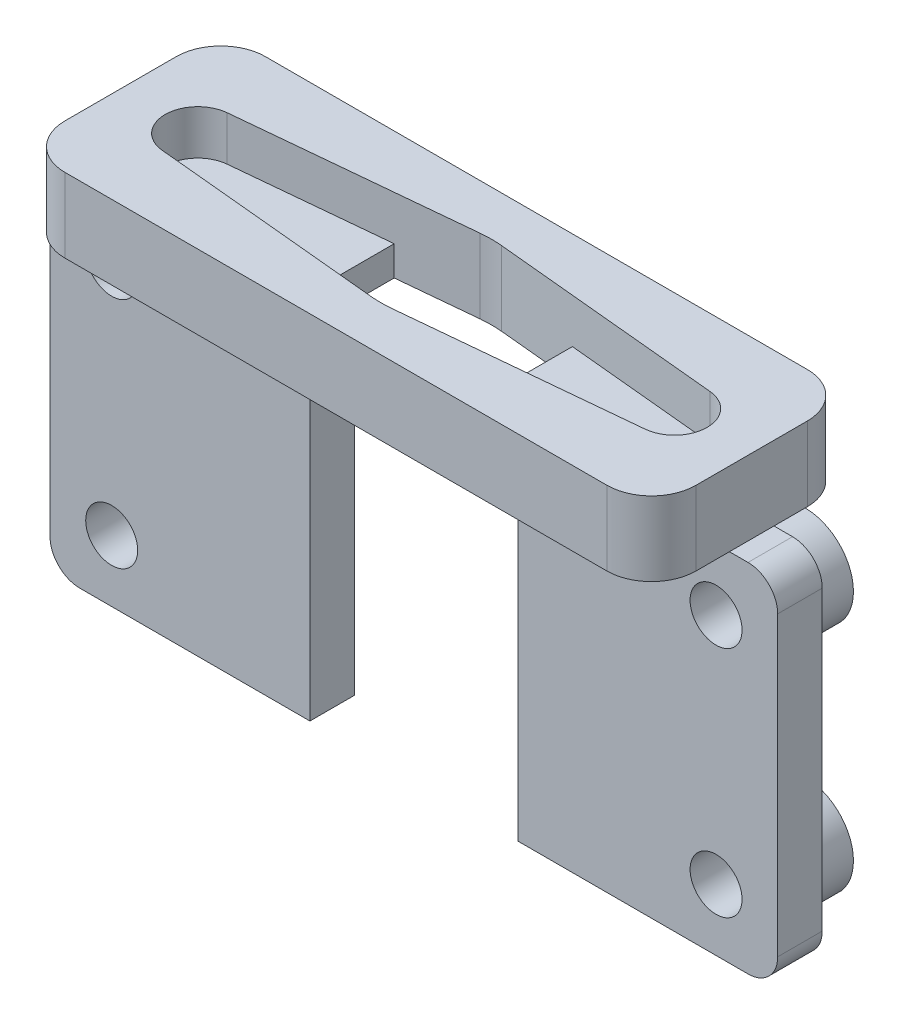
from build123d import *

# Parameters (mm, degrees)
BOSS_EXTRUDE1_DEPTH = 5
BOSS_EXTRUDE2_DEPTH = 2
SKETCH4_W           = 24
SKETCH4_H           = 3
BOSS_EXTRUDE3_DEPTH = 49
CUT_EXTRUDE1_REACH  = 10.25
SKETCH5_R           = 1.75
SKETCH5_W           = 14
SKETCH5_H           = 24
SKETCH6_R           = 3.25
SKETCH6_R_2         = 1.75
BOSS_EXTRUDE4_DEPTH = 3
FILLET1_R           = 2


with BuildPart() as part:
    # Sketch1 → Boss-Extrude1 (new body)
    with BuildSketch(Plane(origin=(0, 0, 0), x_dir=(1, 0, 0), z_dir=(0, 1, 0))):
        with BuildLine():
            Line((-18.25, 6.75), (18.25, 6.75))
            ThreePointArc((18.25, 6.75), (20.371320344, 5.871320344), (21.25, 3.75))
            Line((21.25, 3.75), (21.25, -3.75))
            ThreePointArc((21.25, -3.75), (20.371320344, -5.871320344), (18.25, -6.75))
            Line((18.25, -6.75), (-18.25, -6.75))
            ThreePointArc((-18.25, -6.75), (-20.371320344, -5.871320344), (-21.25, -3.75))
            Line((-21.25, -3.75), (-21.25, 3.75))
            ThreePointArc((-21.25, 3.75), (-20.371320344, 5.871320344), (-18.25, 6.75))
        make_face()
        with BuildLine():
            Line((16.260111444, 2.189943648), (0.716289014, 3.681276533))
            ThreePointArc((0.716289014, 3.681276533), (0, 3.715559552), (-0.716289014, 3.681276533))
            Line((-0.716289014, 3.681276533), (-16.260111444, 2.189943648))
            ThreePointArc((-16.260111444, 2.189943648), (-18.25, 0), (-16.260111444, -2.189943648))
            Line((-16.260111444, -2.189943648), (-0.716289014, -3.681276533))
            ThreePointArc((-0.716289014, -3.681276533), (0, -3.715559552), (0.716289014, -3.681276533))
            Line((0.716289014, -3.681276533), (16.260111444, -2.189943648))
            ThreePointArc((16.260111444, -2.189943648), (18.25, 0), (16.260111444, 2.189943648))
        make_face(mode=Mode.SUBTRACT)
    extrude(amount=BOSS_EXTRUDE1_DEPTH)

    # Sketch2 → Boss-Extrude2 (add)
    with BuildSketch(Plane.XZ):
        with BuildLine():
            Line((-16.260111444, 2.189943648), (-6, 3.174337395))
            Line((-6, 3.174337395), (-6, -3.174337395))
            Line((-6, -3.174337395), (-16.260111444, -2.189943648))
            ThreePointArc((-16.260111444, -2.189943648), (-18.25, 0), (-16.260111444, 2.189943648))
        make_face()
        with BuildLine():
            Line((6, -3.174337395), (16.260111444, -2.189943648))
            ThreePointArc((16.260111444, -2.189943648), (18.25, 0), (16.260111444, 2.189943648))
            Line((16.260111444, 2.189943648), (6, 3.174337395))
            Line((6, 3.174337395), (6, -3.174337395))
        make_face()
    extrude(amount=-BOSS_EXTRUDE2_DEPTH)

    # Sketch4 → Boss-Extrude3 (add)
    with BuildSketch(Plane(origin=(24.5, 24.5, 0), x_dir=(0, -1, 0), z_dir=(-1, 0, 0))):
        with Locations((36.5, 0)):
            Rectangle(SKETCH4_W, SKETCH4_H)
    extrude(amount=BOSS_EXTRUDE3_DEPTH)

    # Sketch5 → Cut-Extrude1 (cut, up to next)
    with BuildSketch(Plane(origin=(0, 0, -1.5), x_dir=(-1, 0, 0), z_dir=(0, 0, -1)), mode=Mode.PRIVATE) as cut_extrude1_sk1:
        with Locations((20.35, -19.85)):
            Circle(SKETCH5_R)
    cut_extrude1_tool1 = extrude(cut_extrude1_sk1.sketch, amount=-CUT_EXTRUDE1_REACH, mode=Mode.PRIVATE) & part.part
    add(cut_extrude1_tool1.solids().sort_by_distance((-20.35, -19.85, -1.5))[0], mode=Mode.SUBTRACT)
    # Sketch5 → Cut-Extrude1 (cut, up to next)
    with BuildSketch(Plane(origin=(0, 0, -1.5), x_dir=(-1, 0, 0), z_dir=(0, 0, -1)), mode=Mode.PRIVATE) as cut_extrude1_sk2:
        with Locations((-20.35, -19.85)):
            Circle(SKETCH5_R)
    cut_extrude1_tool2 = extrude(cut_extrude1_sk2.sketch, amount=-CUT_EXTRUDE1_REACH, mode=Mode.PRIVATE) & part.part
    add(cut_extrude1_tool2.solids().sort_by_distance((20.35, -19.85, -1.5))[0], mode=Mode.SUBTRACT)
    # Sketch5 → Cut-Extrude1 (cut, up to next)
    with BuildSketch(Plane(origin=(0, 0, -1.5), x_dir=(-1, 0, 0), z_dir=(0, 0, -1)), mode=Mode.PRIVATE) as cut_extrude1_sk3:
        with Locations((-20.35, -4.15)):
            Circle(SKETCH5_R)
    cut_extrude1_tool3 = extrude(cut_extrude1_sk3.sketch, amount=-CUT_EXTRUDE1_REACH, mode=Mode.PRIVATE) & part.part
    add(cut_extrude1_tool3.solids().sort_by_distance((20.35, -4.15, -1.5))[0], mode=Mode.SUBTRACT)
    # Sketch5 → Cut-Extrude1 (cut, up to next)
    with BuildSketch(Plane(origin=(0, 0, -1.5), x_dir=(-1, 0, 0), z_dir=(0, 0, -1)), mode=Mode.PRIVATE) as cut_extrude1_sk4:
        with Locations((20.35, -4.15)):
            Circle(SKETCH5_R)
    cut_extrude1_tool4 = extrude(cut_extrude1_sk4.sketch, amount=-CUT_EXTRUDE1_REACH, mode=Mode.PRIVATE) & part.part
    add(cut_extrude1_tool4.solids().sort_by_distance((-20.35, -4.15, -1.5))[0], mode=Mode.SUBTRACT)
    # Sketch5 → Cut-Extrude1 (cut, up to next)
    with BuildSketch(Plane(origin=(0, 0, -1.5), x_dir=(-1, 0, 0), z_dir=(0, 0, -1)), mode=Mode.PRIVATE) as cut_extrude1_sk5:
        with Locations((0, -12)):
            Rectangle(SKETCH5_W, SKETCH5_H)
    cut_extrude1_tool5 = extrude(cut_extrude1_sk5.sketch, amount=-CUT_EXTRUDE1_REACH, mode=Mode.PRIVATE) & part.part
    add(cut_extrude1_tool5.solids().sort_by_distance((0, -12, -1.5))[0], mode=Mode.SUBTRACT)

    # Sketch6 → Boss-Extrude4 (add)
    with BuildSketch(Plane(origin=(0, 0, -1.5), x_dir=(-1, 0, 0), z_dir=(0, 0, -1))):
        with Locations((-20.35, -4.15)):
            Circle(SKETCH6_R)
        with Locations((-20.35, -4.15)):
            Circle(SKETCH6_R_2, mode=Mode.SUBTRACT)
        with Locations((20.35, -4.15)):
            Circle(SKETCH6_R)
        with Locations((20.35, -4.15)):
            Circle(SKETCH6_R_2, mode=Mode.SUBTRACT)
        with Locations((20.35, -19.85)):
            Circle(SKETCH6_R)
        with Locations((20.35, -19.85)):
            Circle(SKETCH6_R_2, mode=Mode.SUBTRACT)
        with Locations((-20.35, -19.85)):
            Circle(SKETCH6_R)
        with Locations((-20.35, -19.85)):
            Circle(SKETCH6_R_2, mode=Mode.SUBTRACT)
    extrude(amount=BOSS_EXTRUDE4_DEPTH)

    # Fillet1
    fillet1_edges = [part.edges().sort_by_distance(p)[0] for p in [
        (24.5, 0, 0),
        (24.5, -24, 0),
        (-24.5, 0, 0),
        (-24.5, -24, 0),
    ]]
    fillet(fillet1_edges, radius=FILLET1_R)


solid = part.part
